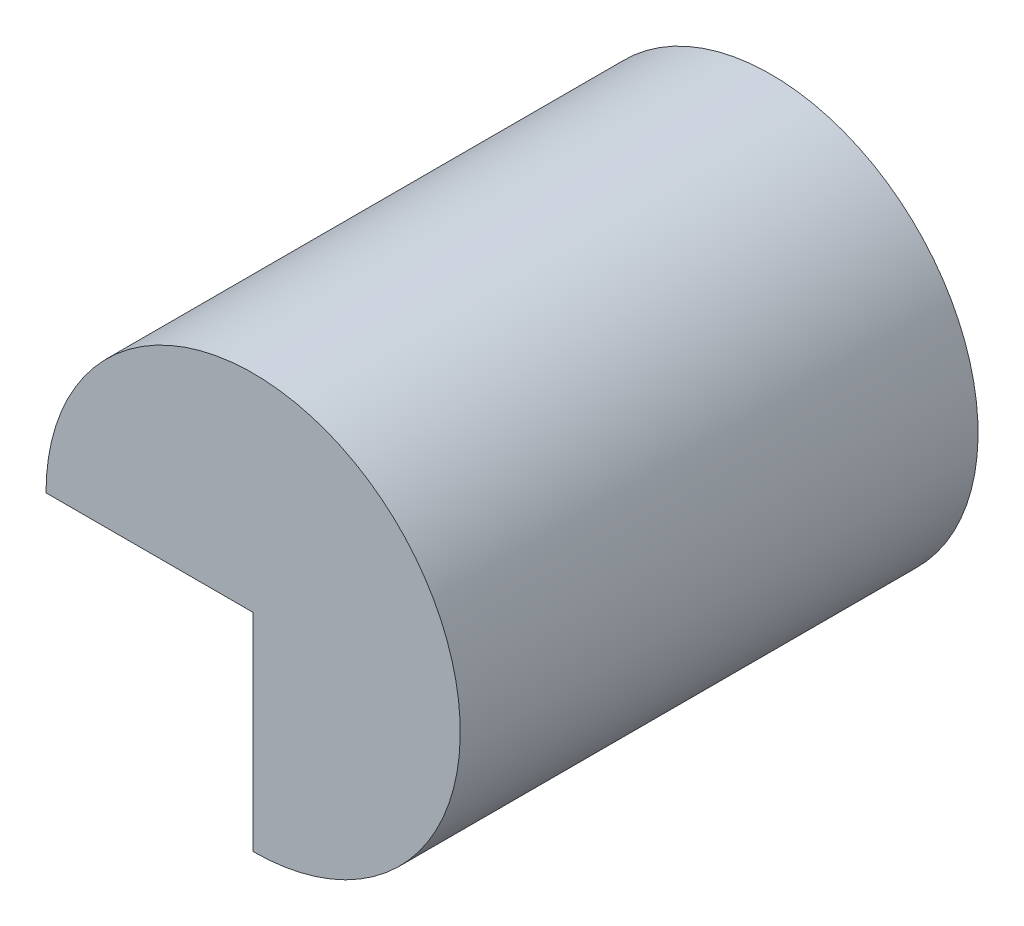
from build123d import *

# Parameters (mm, degrees)
BOSS_EXTRUDE1_DEPTH = 25


with BuildPart() as part:
    # Sketch1 → Boss-Extrude1 (new body)
    with BuildSketch(Plane.XY):
        with BuildLine():
            Line((-10, 0), (0, 0))
            Line((0, 0), (0, -10))
            ThreePointArc((0, -10), (7.071067812, 7.071067812), (-10, 0))
        make_face()
    extrude(amount=BOSS_EXTRUDE1_DEPTH)


solid = part.part
